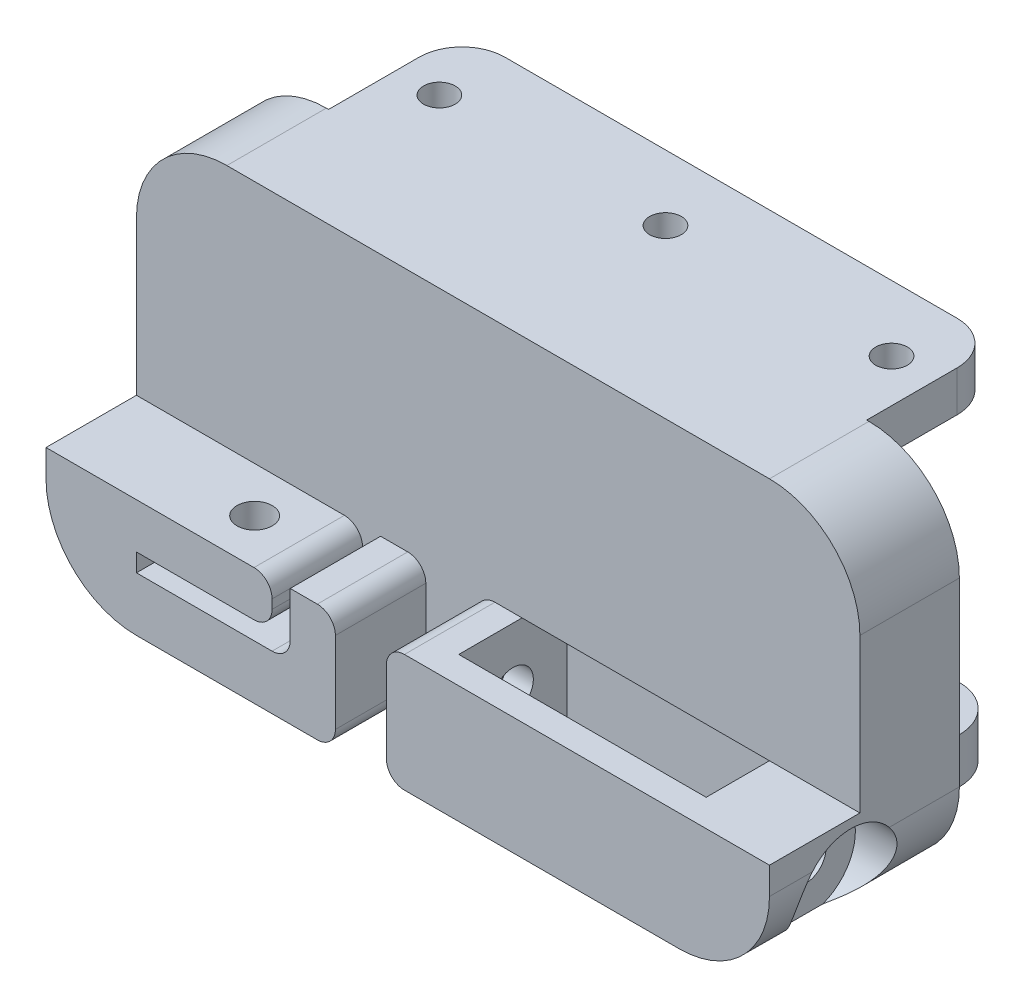
from build123d import *

# Parameters (mm, degrees)
BOSS_EXTRUDE1_DEPTH      = 11
SKETCH2_W                = 60
SKETCH2_H                = 5
BOSS_EXTRUDE2_DEPTH      = 26
FILLET1_R                = 5
SKETCH4_R                = 1.75
CUT_EXTRUDE2_DEPTH       = 25
CUT_EXTRUDE3_DEPTH       = 25
FILLET1_OF_MIRROR1_R     = 5
CUT_EXTRUDE7_DEPTH       = 0.5
BOSS_EXTRUDE3_DEPTH      = 10
SKETCH20_R               = 1.95
CUT_EXTRUDE10_DEPTH      = 14
FILLET2_R                = 2
SKETCH21_W               = 5
SKETCH21_H               = 13
BOSS_EXTRUDE4_DEPTH      = 10
FILLET3_R                = 2
FILLET4_R                = 2
SKETCH24_W               = 27.361524014
SKETCH24_H               = 13
CUT_EXTRUDE12_DEPTH      = 5
SKETCH22_R               = 2.25
CUT_EXTRUDE11_DEPTH      = 38.361524014
CUT_EXTRUDE11_DEPTH_BACK = 3
SKETCH23_R               = 5.5
CUT_EXTRUDE13_DEPTH      = 5
BOSS_EXTRUDE5_DEPTH      = 3
FILLET5_R                = 2


with BuildPart() as part:
    # Sketch1 → Boss-Extrude1 (new body)
    with BuildSketch(Plane.XY):
        with BuildLine():
            Line((60, 35), (0, 35))
            Line((0, 35), (0, 40))
            ThreePointArc((0, 40), (-7.071067812, 37.071067812), (-10, 30))
            Line((-10, 30), (-10, 10))
            ThreePointArc((-10, 10), (-7.071067812, 2.928932188), (0, 0))
            Line((0, 0), (60, 0))
            ThreePointArc((60, 0), (67.071067812, 2.928932188), (70, 10))
            Line((70, 10), (70, 30))
            ThreePointArc((70, 30), (67.071067812, 37.071067812), (60, 40))
            Line((60, 40), (60, 35))
        make_face()
    extrude(amount=BOSS_EXTRUDE1_DEPTH)

    # Sketch2 → Boss-Extrude2 (add)
    with BuildSketch(Plane.XY.offset(11)):
        with Locations((30, 37.5)):
            Rectangle(SKETCH2_W, SKETCH2_H)
    boss_extrude2 = extrude(amount=-BOSS_EXTRUDE2_DEPTH)

    # Fillet1
    fillet1_edges = [part.edges().sort_by_distance(p)[0] for p in [
        (0, 37.5, -15),
        (60, 37.5, -15),
    ]]
    fillet(fillet1_edges, radius=FILLET1_R)

    # Sketch4 → Cut-Extrude2 (cut)
    with BuildSketch(Plane(origin=(0, 35, 0), x_dir=(-1, 0, 0), z_dir=(0, -1, 0))):
        with Locations((-55, 7.5)):
            Circle(SKETCH4_R)
        with Locations((-30, 7.5)):
            Circle(SKETCH4_R)
        with Locations((-5, 7.5)):
            Circle(SKETCH4_R)
    cut_extrude2 = extrude(amount=-CUT_EXTRUDE2_DEPTH, mode=Mode.SUBTRACT)

    # Sketch5 → Cut-Extrude3 (cut)
    with BuildSketch(Plane.XZ.offset(-35)):
        with BuildLine():
            Line((5, -14.75), (55, -14.75))
            ThreePointArc((55, -14.75), (58.358757211, -13.358757211), (59.75, -10))
            Line((59.75, -10), (59.75, -0.25))
            Line((59.75, -0.25), (59.75, 0))
            Line((59.75, 0), (60, 0))
            Line((60, 0), (60, -10))
            ThreePointArc((60, -10), (58.535533906, -13.535533906), (55, -15))
            Line((55, -15), (5, -15))
            ThreePointArc((5, -15), (1.464466094, -13.535533906), (0, -10))
            Line((0, -10), (0, 0))
            Line((0, 0), (0.25, 0))
            Line((0.25, 0), (0.25, -0.25))
            Line((0.25, -0.25), (0.25, -10))
            ThreePointArc((0.25, -10), (1.641242789, -13.358757211), (5, -14.75))
        make_face()
    extrude(amount=-CUT_EXTRUDE3_DEPTH, mode=Mode.SUBTRACT)

    # Mirror1: Boss-Extrude2, Cut-Extrude2 across plane
    add(boss_extrude2.mirror(Plane(origin=(0, 20, 0), x_dir=(0, 0, 1), z_dir=(0, -1, 0))))
    add(cut_extrude2.mirror(Plane(origin=(0, 20, 0), x_dir=(0, 0, 1), z_dir=(0, -1, 0))), mode=Mode.SUBTRACT)

    # Fillet1 of Mirror1
    fillet1_of_mirror1_edges = [part.edges().sort_by_distance(p)[0] for p in [
        (0, 2.5, -15),
        (60, 2.5, -15),
    ]]
    fillet(fillet1_of_mirror1_edges, radius=FILLET1_OF_MIRROR1_R)

    # Sketch16 → Cut-Extrude7 (cut)
    with BuildSketch(Plane.XZ.offset(-35)):
        with BuildLine():
            Line((0.25, 0), (0.25, -10))
            ThreePointArc((0.25, -10), (1.641242789, -13.358757211), (5, -14.75))
            Line((5, -14.75), (55, -14.75))
            ThreePointArc((55, -14.75), (58.358757211, -13.358757211), (59.75, -10))
            Line((59.75, -10), (59.75, 0))
            Line((59.75, 0), (0.25, 0))
        make_face()
    extrude(amount=-CUT_EXTRUDE7_DEPTH, mode=Mode.SUBTRACT)

    # Sketch19 → Boss-Extrude3 (add)
    with BuildSketch(Plane.XY.offset(11)):
        with BuildLine():
            Line((-10, 13), (15, 13))
            Line((15, 13), (15, 9.995431427))
            ThreePointArc((15, 9.995431427), (14.414213562, 8.581217864), (13, 7.995431427))
            Line((13, 7.995431427), (0, 7.995431427))
            Line((0, 7.995431427), (0, 5.995431427))
            Line((0, 5.995431427), (15, 5.995431427))
            ThreePointArc((15, 5.995431427), (16.414213562, 6.581217864), (17, 7.995431427))
            Line((17, 7.995431427), (17, 13))
            Line((17, 13), (22, 13))
            Line((22, 13), (22, 0))
            Line((22, 0), (0, 0))
            ThreePointArc((0, 0), (-7.071067812, 2.928932188), (-10, 10))
            Line((-10, 10), (-10, 13))
        make_face()
    extrude(amount=BOSS_EXTRUDE3_DEPTH)

    # Sketch20 → Cut-Extrude10 (cut)
    with BuildSketch(Plane(origin=(0, 0, 0), x_dir=(-1, 0, 0), z_dir=(0, -1, 0))):
        with Locations((-8.068741, -16)):
            Circle(SKETCH20_R)
    extrude(amount=-CUT_EXTRUDE10_DEPTH, mode=Mode.SUBTRACT)

    # Fillet2
    fillet2_edges = [part.edges().sort_by_distance(p)[0] for p in [
        (15, 13, 16),
    ]]
    fillet(fillet2_edges, radius=FILLET2_R)

    # Sketch21 → Boss-Extrude4 (add)
    with BuildSketch(Plane.XY.offset(11)):
        with BuildLine():
            Line((70, 13), (60, 13))
            Line((60, 13), (60, 0))
            ThreePointArc((60, 0), (67.071067812, 2.928932188), (70, 10))
            Line((70, 10), (70, 13))
        make_face()
        with Locations((30.138475986, 6.5)):
            Rectangle(SKETCH21_W, SKETCH21_H)
    extrude(amount=BOSS_EXTRUDE4_DEPTH)

    # Fillet3
    fillet3_edges = [part.edges().sort_by_distance(p)[0] for p in [
        (27.638475986, 13, 16),
    ]]
    fillet(fillet3_edges, radius=FILLET3_R)

    # Fillet4
    fillet4_edges = [part.edges().sort_by_distance(p)[0] for p in [
        (27.638475986, 0, 16),
    ]]
    fillet(fillet4_edges, radius=FILLET4_R)

    # Sketch24 → Cut-Extrude12 (cut)
    with BuildSketch(Plane.XY.offset(11)):
        with Locations((46.319237993, 6.5)):
            Rectangle(SKETCH24_W, SKETCH24_H)
    extrude(amount=-CUT_EXTRUDE12_DEPTH, mode=Mode.SUBTRACT)

    # Sketch22 → Cut-Extrude11 (cut, two sides)
    with BuildSketch(Plane(origin=(32.638475986, 0, 0), x_dir=(0, 0, -1), z_dir=(1, 0, 0))) as cut_extrude11_sk:
        with Locations((-12, 6.5)):
            Circle(SKETCH22_R)
    extrude(amount=CUT_EXTRUDE11_DEPTH, mode=Mode.SUBTRACT)
    extrude(cut_extrude11_sk.sketch, amount=-CUT_EXTRUDE11_DEPTH_BACK, mode=Mode.SUBTRACT)

    # Sketch23 → Cut-Extrude13 (cut)
    with BuildSketch(Plane(origin=(70, 0, 0), x_dir=(0, 0, -1), z_dir=(1, 0, 0))):
        with Locations((-12, 6.5)):
            Circle(SKETCH23_R)
    extrude(amount=-CUT_EXTRUDE13_DEPTH, mode=Mode.SUBTRACT)

    # Sketch25 → Boss-Extrude5 (add)
    with BuildSketch(Plane.XY.offset(21)):
        with BuildLine():
            Line((60, 0), (32.638475986, 0))
            Line((32.638475986, 0), (29.638475986, 0))
            ThreePointArc((29.638475986, 0), (28.224262424, 0.585786438), (27.638475986, 2))
            Line((27.638475986, 2), (27.638475986, 11))
            ThreePointArc((27.638475986, 11), (28.224262424, 12.414213562), (29.638475986, 13))
            Line((29.638475986, 13), (32.638475986, 13))
            Line((32.638475986, 13), (60, 13))
            Line((60, 13), (70, 13))
            Line((70, 13), (70, 10))
            ThreePointArc((70, 10), (67.071067812, 2.928932188), (60, 0))
        make_face()
    extrude(amount=-BOSS_EXTRUDE5_DEPTH)

    # Fillet5
    fillet5_edges = [part.edges().sort_by_distance(p)[0] for p in [
        (22, 0, 16),
        (22, 13, 16),
    ]]
    fillet(fillet5_edges, radius=FILLET5_R)


solid = part.part
